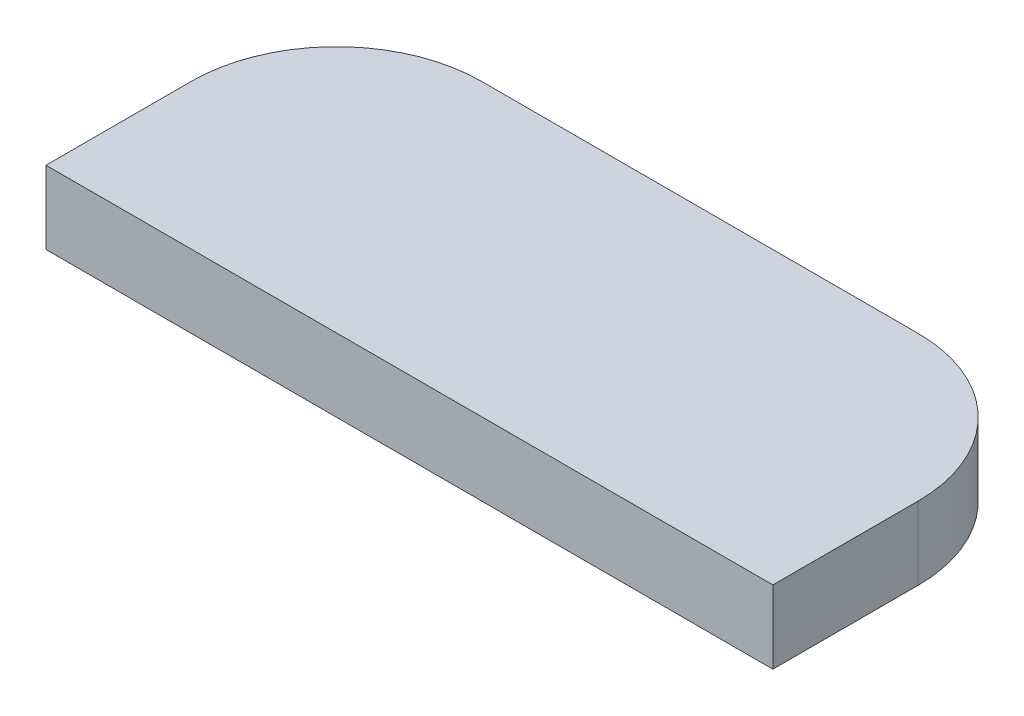
from build123d import *

# Parameters (mm, degrees)
BOSS_EXTRUDE1_DEPTH = 11.176


with BuildPart() as part:
    # Sketch2 → Boss-Extrude1 (new body)
    with BuildSketch(Plane(origin=(0, 0, 0), x_dir=(1, 0, 0), z_dir=(0, 1, 0))):
        with BuildLine():
            Line((55.626, 0), (-55.626, 0))
            Line((-55.626, 0), (-55.626, 22.225))
            ThreePointArc((-55.626, 22.225), (-49.116448212, 37.940448212), (-33.401, 44.45))
            Line((-33.401, 44.45), (33.401, 44.45))
            ThreePointArc((33.401, 44.45), (49.116448212, 37.940448212), (55.626, 22.225))
            Line((55.626, 22.225), (55.626, 0))
        make_face()
    extrude(amount=BOSS_EXTRUDE1_DEPTH)


solid = part.part
